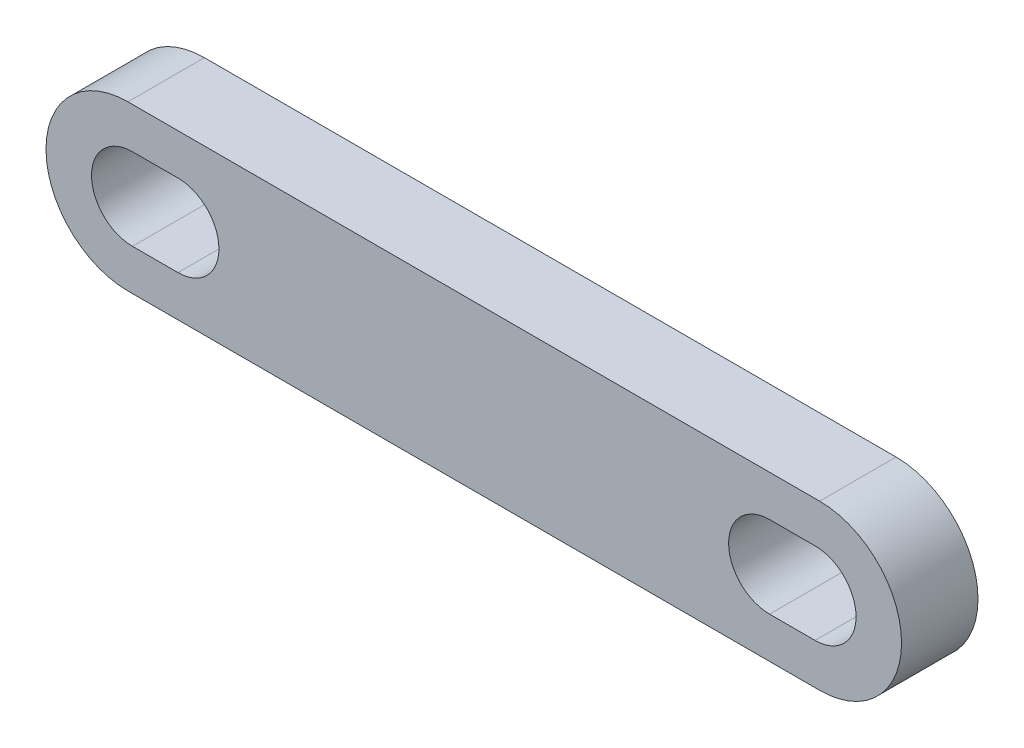
from build123d import *

# Parameters (mm, degrees)
SALIENTE_EXTRUIR2_DEPTH = 4.2


with BuildPart() as part:
    # Croquis1 → Saliente-Extruir2 (new body)
    with BuildSketch(Plane.XY):
        with BuildLine():
            Line((19, 4.5), (-19, 4.5))
            ThreePointArc((-19, 4.5), (-23.5, 0), (-19, -4.5))
            Line((-19, -4.5), (19, -4.5))
            ThreePointArc((19, -4.5), (23.5, 0), (19, 4.5))
        make_face()
        with BuildLine():
            Line((18.75, 2.25), (16.25, 2.25))
            ThreePointArc((16.25, 2.25), (14, 0), (16.25, -2.25))
            Line((16.25, -2.25), (18.75, -2.25))
            ThreePointArc((18.75, -2.25), (21, 0), (18.75, 2.25))
        make_face(mode=Mode.SUBTRACT)
        with BuildLine():
            Line((-16.25, 2.25), (-18.75, 2.25))
            ThreePointArc((-18.75, 2.25), (-21, 0), (-18.75, -2.25))
            Line((-18.75, -2.25), (-16.25, -2.25))
            ThreePointArc((-16.25, -2.25), (-14, 0), (-16.25, 2.25))
        make_face(mode=Mode.SUBTRACT)
    extrude(amount=SALIENTE_EXTRUIR2_DEPTH)


solid = part.part
